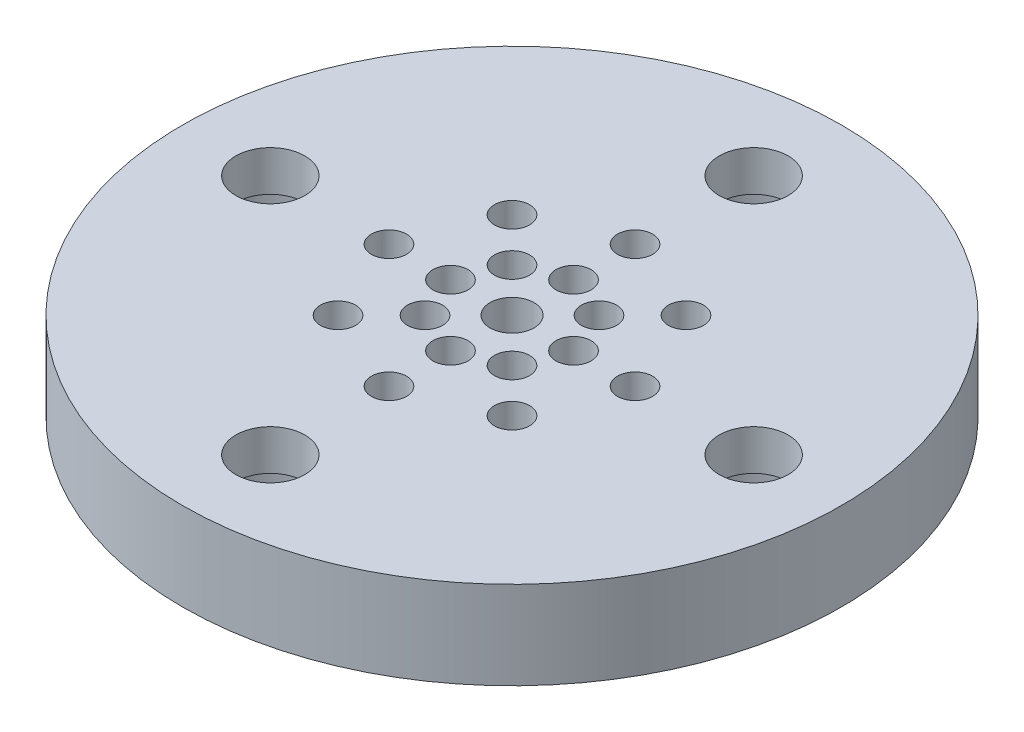
from build123d import *

# Parameters (mm, degrees)
SKETCH1_R                                           = 50.8
BOSS_EXTRUDE1_DEPTH                                 = 25.4
SKETCH2_R                                           = 69.85
SKETCH2_R_2                                         = 50.8
BOSS_EXTRUDE2_DEPTH                                 = 12.7
SKETCH3_R                                           = 49.53
SKETCH3_R_2                                         = 47.625
CUT_EXTRUDE1_DEPTH                                  = 1.1176
CUT_EXTRUDE2_REACH                                  = 27.4
SKETCH4_R                                           = 3.175
SKETCH5_R                                           = 11.43
CUT_EXTRUDE3_DEPTH                                  = 19.05
CUT_EXTRUDE4_REACH                                  = 8.35
SKETCH6_R                                           = 1.5875
SKETCH42_OUTSIDE_W                                  = 181.538
SKETCH42_OUTSIDE_H                                  = 181.538
SKETCH42_OUTSIDE_R                                  = 23.8125
CUT_EXTRUDE9_DEPTH                                  = 30.48
SKETCH43_R                                          = 20.6375
CUT_EXTRUDE10_DEPTH                                 = 19.05
CBORE_FOR_10_BINDING_HEAD_MACHINE_SCREW_D           = 4.9784
CBORE_FOR_10_BINDING_HEAD_MACHINE_SCREW_CBORE_D     = 9.525
CBORE_FOR_10_BINDING_HEAD_MACHINE_SCREW_CBORE_DEPTH = 3.429
SKETCH52_R                                          = 23.8125
CUT_EXTRUDE11_DEPTH                                 = 19.05
SKETCH54_R                                          = 1.27
CUT_EXTRUDE12_DEPTH                                 = 6.35
CIRPATTERN1_COUNT                                   = 8
SKETCH55_R                                          = 1.27
CUT_EXTRUDE13_DEPTH                                 = 6.35
CIRPATTERN2_COUNT                                   = 8


with BuildPart() as part:
    # Sketch1 → Boss-Extrude1 (new body)
    with BuildSketch(Plane(origin=(0, 0, 0), x_dir=(1, 0, 0), z_dir=(0, 1, 0))):
        Circle(SKETCH1_R)
    extrude(amount=BOSS_EXTRUDE1_DEPTH)

    # Sketch2 → Boss-Extrude2 (add)
    with BuildSketch(Plane.XZ):
        Circle(SKETCH2_R)
        Circle(SKETCH2_R_2, mode=Mode.SUBTRACT)
    extrude(amount=-BOSS_EXTRUDE2_DEPTH)

    # Sketch3 → Cut-Extrude1 (cut)
    with BuildSketch(Plane.XZ):
        Circle(SKETCH3_R)
        Circle(SKETCH3_R_2, mode=Mode.SUBTRACT)
    extrude(amount=-CUT_EXTRUDE1_DEPTH, mode=Mode.SUBTRACT)

    # Sketch4 → Cut-Extrude2 (cut, up to next)
    with BuildSketch(Plane.XZ, mode=Mode.PRIVATE) as cut_extrude2_sk1:
        with Locations((0, -59.9186)):
            Circle(SKETCH4_R)
    cut_extrude2_tool1 = extrude(cut_extrude2_sk1.sketch, amount=-CUT_EXTRUDE2_REACH, mode=Mode.PRIVATE) & part.part
    add(cut_extrude2_tool1.solids().sort_by_distance((0, 0, -59.9186))[0], mode=Mode.SUBTRACT)
    # Sketch4 → Cut-Extrude2 (cut, up to next)
    with BuildSketch(Plane.XZ, mode=Mode.PRIVATE) as cut_extrude2_sk2:
        with Locations((-42.368848379, -42.368848379)):
            Circle(SKETCH4_R)
    cut_extrude2_tool2 = extrude(cut_extrude2_sk2.sketch, amount=-CUT_EXTRUDE2_REACH, mode=Mode.PRIVATE) & part.part
    add(cut_extrude2_tool2.solids().sort_by_distance((-42.368848, 0, -42.368848))[0], mode=Mode.SUBTRACT)
    # Sketch4 → Cut-Extrude2 (cut, up to next)
    with BuildSketch(Plane.XZ, mode=Mode.PRIVATE) as cut_extrude2_sk3:
        with Locations((-59.9186, 0)):
            Circle(SKETCH4_R)
    cut_extrude2_tool3 = extrude(cut_extrude2_sk3.sketch, amount=-CUT_EXTRUDE2_REACH, mode=Mode.PRIVATE) & part.part
    add(cut_extrude2_tool3.solids().sort_by_distance((-59.9186, 0, 0))[0], mode=Mode.SUBTRACT)
    # Sketch4 → Cut-Extrude2 (cut, up to next)
    with BuildSketch(Plane.XZ, mode=Mode.PRIVATE) as cut_extrude2_sk4:
        with Locations((-42.368848379, 42.368848379)):
            Circle(SKETCH4_R)
    cut_extrude2_tool4 = extrude(cut_extrude2_sk4.sketch, amount=-CUT_EXTRUDE2_REACH, mode=Mode.PRIVATE) & part.part
    add(cut_extrude2_tool4.solids().sort_by_distance((-42.368848, 0, 42.368848))[0], mode=Mode.SUBTRACT)
    # Sketch4 → Cut-Extrude2 (cut, up to next)
    with BuildSketch(Plane.XZ, mode=Mode.PRIVATE) as cut_extrude2_sk5:
        with Locations((0, 59.9186)):
            Circle(SKETCH4_R)
    cut_extrude2_tool5 = extrude(cut_extrude2_sk5.sketch, amount=-CUT_EXTRUDE2_REACH, mode=Mode.PRIVATE) & part.part
    add(cut_extrude2_tool5.solids().sort_by_distance((0, 0, 59.9186))[0], mode=Mode.SUBTRACT)
    # Sketch4 → Cut-Extrude2 (cut, up to next)
    with BuildSketch(Plane.XZ, mode=Mode.PRIVATE) as cut_extrude2_sk6:
        with Locations((42.368848379, 42.368848379)):
            Circle(SKETCH4_R)
    cut_extrude2_tool6 = extrude(cut_extrude2_sk6.sketch, amount=-CUT_EXTRUDE2_REACH, mode=Mode.PRIVATE) & part.part
    add(cut_extrude2_tool6.solids().sort_by_distance((42.368848, 0, 42.368848))[0], mode=Mode.SUBTRACT)
    # Sketch4 → Cut-Extrude2 (cut, up to next)
    with BuildSketch(Plane.XZ, mode=Mode.PRIVATE) as cut_extrude2_sk7:
        with Locations((59.9186, 0)):
            Circle(SKETCH4_R)
    cut_extrude2_tool7 = extrude(cut_extrude2_sk7.sketch, amount=-CUT_EXTRUDE2_REACH, mode=Mode.PRIVATE) & part.part
    add(cut_extrude2_tool7.solids().sort_by_distance((59.9186, 0, 0))[0], mode=Mode.SUBTRACT)
    # Sketch4 → Cut-Extrude2 (cut, up to next)
    with BuildSketch(Plane.XZ, mode=Mode.PRIVATE) as cut_extrude2_sk8:
        with Locations((42.368848379, -42.368848379)):
            Circle(SKETCH4_R)
    cut_extrude2_tool8 = extrude(cut_extrude2_sk8.sketch, amount=-CUT_EXTRUDE2_REACH, mode=Mode.PRIVATE) & part.part
    add(cut_extrude2_tool8.solids().sort_by_distance((42.368848, 0, -42.368848))[0], mode=Mode.SUBTRACT)

    # Sketch5 → Cut-Extrude3 (cut)
    with BuildSketch(Plane(origin=(0, 25.4, 0), x_dir=(1, 0, 0), z_dir=(0, 1, 0))):
        Circle(SKETCH5_R)
    extrude(amount=-CUT_EXTRUDE3_DEPTH, mode=Mode.SUBTRACT)

    # Sketch6 → Cut-Extrude4 (cut, up to next)
    with BuildSketch(Plane(origin=(0, 6.35, 0), x_dir=(1, 0, 0), z_dir=(0, 1, 0)), mode=Mode.PRIVATE) as cut_extrude4_sk1:
        Circle(SKETCH6_R)
    cut_extrude4_tool1 = extrude(cut_extrude4_sk1.sketch, amount=-CUT_EXTRUDE4_REACH, mode=Mode.PRIVATE) & part.part
    add(cut_extrude4_tool1.solids().sort_by_distance((0, 6.35, 0))[0], mode=Mode.SUBTRACT)

    # Sketch42 outside → Cut-Extrude9 (cut)
    with BuildSketch(Plane.XZ):
        Rectangle(SKETCH42_OUTSIDE_W, SKETCH42_OUTSIDE_H)
        Circle(SKETCH42_OUTSIDE_R, mode=Mode.SUBTRACT)
    extrude(amount=-CUT_EXTRUDE9_DEPTH, mode=Mode.SUBTRACT)

    # Sketch43 → Cut-Extrude10 (cut)
    with BuildSketch(Plane(origin=(0, 25.4, 0), x_dir=(1, 0, 0), z_dir=(0, 1, 0))):
        Circle(SKETCH43_R)
    extrude(amount=-CUT_EXTRUDE10_DEPTH, mode=Mode.SUBTRACT)

    # CBORE for #10 Binding Head Machine Screw1 (through all)
    with Locations(Plane(origin=(0, 0, 0), x_dir=(-1, 0, 0), z_dir=(0, -1, 0))):
        with Locations((0, -17.4625), (-17.4625, 0), (17.4625, 0), (0, 17.4625)):
            CounterBoreHole(CBORE_FOR_10_BINDING_HEAD_MACHINE_SCREW_D / 2, CBORE_FOR_10_BINDING_HEAD_MACHINE_SCREW_CBORE_D / 2, CBORE_FOR_10_BINDING_HEAD_MACHINE_SCREW_CBORE_DEPTH)

    # Sketch52 → Cut-Extrude11 (cut)
    with BuildSketch(Plane(origin=(0, 25.4, 0), x_dir=(1, 0, 0), z_dir=(0, 1, 0))):
        Circle(SKETCH52_R)
    extrude(amount=-CUT_EXTRUDE11_DEPTH, mode=Mode.SUBTRACT)

    # Sketch54 → Cut-Extrude12 (cut)
    with BuildSketch(Plane(origin=(0, 6.35, 0), x_dir=(1, 0, 0), z_dir=(0, 1, 0))):
        with Locations((0, -4.445)):
            Circle(SKETCH54_R)
    cut_extrude12 = extrude(amount=-CUT_EXTRUDE12_DEPTH, mode=Mode.SUBTRACT)

    # CirPattern1: Cut-Extrude12 ×8 about axis
    cirpattern1_axis = Axis((0, 0, 0), (0, 1, 0))
    for i in range(1, CIRPATTERN1_COUNT):
        add(cut_extrude12.rotate(cirpattern1_axis, i * 360 / CIRPATTERN1_COUNT), mode=Mode.SUBTRACT)

    # Sketch55 → Cut-Extrude13 (cut)
    with BuildSketch(Plane(origin=(0, 6.35, 0), x_dir=(1, 0, 0), z_dir=(0, 1, 0))):
        with Locations((0, -8.89)):
            Circle(SKETCH55_R)
    cut_extrude13 = extrude(amount=-CUT_EXTRUDE13_DEPTH, mode=Mode.SUBTRACT)

    # CirPattern2: Cut-Extrude13 ×8 about axis
    cirpattern2_axis = Axis((0, 0, 0), (0, 1, 0))
    for i in range(1, CIRPATTERN2_COUNT):
        add(cut_extrude13.rotate(cirpattern2_axis, i * 360 / CIRPATTERN2_COUNT), mode=Mode.SUBTRACT)


solid = part.part
